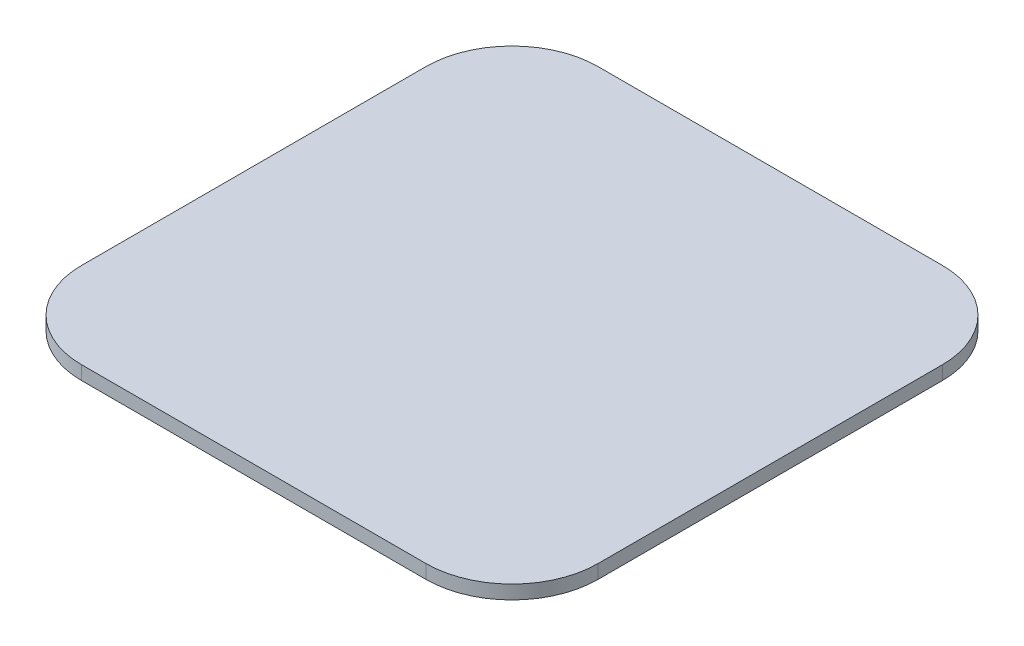
from build123d import *

# Parameters (mm, degrees)
SKETCH1_R           = 5
BOSS_EXTRUDE1_DEPTH = 0.2
SKETCH2_W           = 15
SKETCH2_H           = 15
BOSS_EXTRUDE2_DEPTH = 0.4
FILLET1_R           = 2.5


with BuildPart() as part:
    # Sketch1 → Boss-Extrude1 (new body)
    with BuildSketch(Plane(origin=(0, 0, 0), x_dir=(1, 0, 0), z_dir=(0, 1, 0))):
        Circle(SKETCH1_R)
    extrude(amount=BOSS_EXTRUDE1_DEPTH)

    # Sketch2 → Boss-Extrude2 (add)
    with BuildSketch(Plane(origin=(0, 0.2, 0), x_dir=(1, 0, 0), z_dir=(0, 1, 0))):
        Rectangle(SKETCH2_W, SKETCH2_H)
    extrude(amount=BOSS_EXTRUDE2_DEPTH)

    # Fillet1
    fillet1_edges = [part.edges().sort_by_distance(p)[0] for p in [
        (7.5, 0.4, 7.5),
        (7.5, 0.4, -7.5),
        (-7.5, 0.4, -7.5),
        (-7.5, 0.4, 7.5),
    ]]
    fillet(fillet1_edges, radius=FILLET1_R)


solid = part.part
